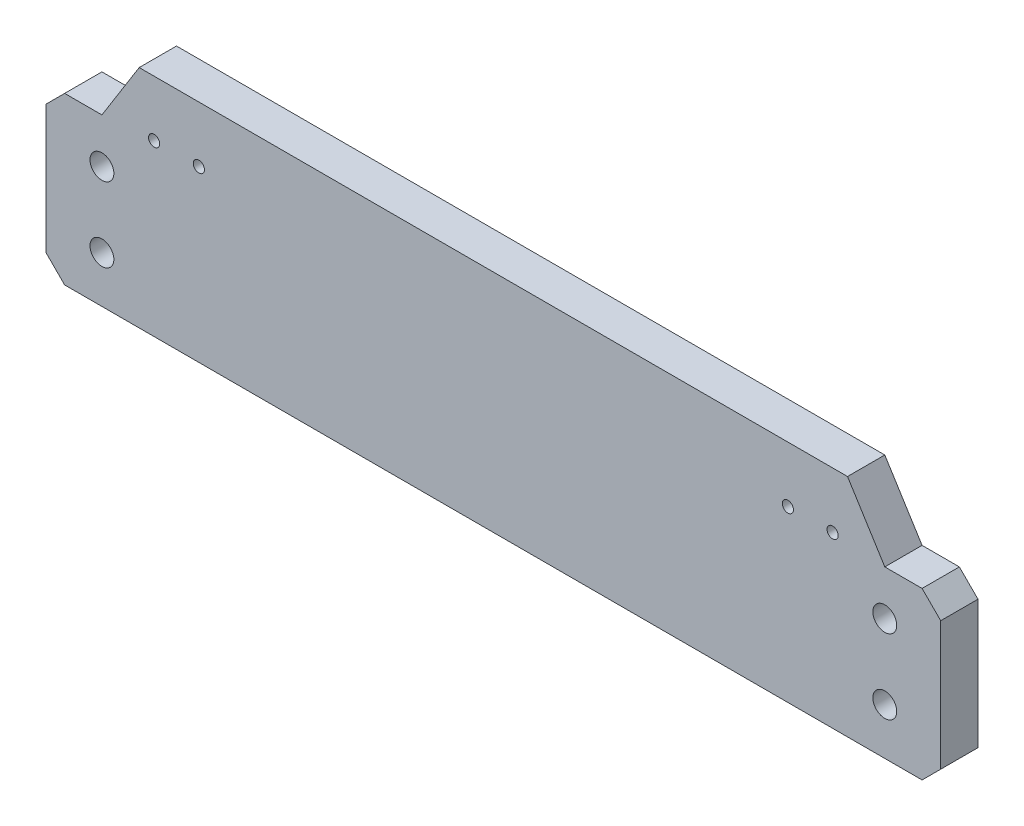
from build123d import *

# Parameters (mm, degrees)
SKETCH1_W           = 240
SKETCH1_H           = 60.5
SKETCH1_R           = 3.2
SKETCH1_R_2         = 1.5
BOSS_EXTRUDE1_DEPTH = 10
CUT_EXTRUDE1_DEPTH  = 11
CHAMFER3_SIZE       = 5


with BuildPart() as part:
    # Sketch1 → Boss-Extrude1 (new body)
    with BuildSketch(Plane.XY):
        Rectangle(SKETCH1_W, SKETCH1_H)
        with Locations((-105, 2.25)):
            Circle(SKETCH1_R, mode=Mode.SUBTRACT)
        with Locations((-105, -17.75)):
            Circle(SKETCH1_R, mode=Mode.SUBTRACT)
        with Locations((105, -17.75)):
            Circle(SKETCH1_R, mode=Mode.SUBTRACT)
        with Locations((105, 2.25)):
            Circle(SKETCH1_R, mode=Mode.SUBTRACT)
        with Locations((-91, 15.25)):
            Circle(SKETCH1_R_2, mode=Mode.SUBTRACT)
        with Locations((-79, 15.25)):
            Circle(SKETCH1_R_2, mode=Mode.SUBTRACT)
        with Locations((79, 15.25)):
            Circle(SKETCH1_R_2, mode=Mode.SUBTRACT)
        with Locations((91, 15.25)):
            Circle(SKETCH1_R_2, mode=Mode.SUBTRACT)
    extrude(amount=BOSS_EXTRUDE1_DEPTH)

    # Sketch2 → Cut-Extrude1 (cut, through all)
    with BuildSketch(Plane.XY.offset(10)):
        Polygon((-120, 14.25), (-105, 14.25), (-95, 30.25), (-120, 30.25), align=None)
        Polygon((120, 30.25), (120, 14.25), (105, 14.25), (95, 30.25), align=None)
    extrude(amount=-CUT_EXTRUDE1_DEPTH, mode=Mode.SUBTRACT)

    # Chamfer3
    chamfer3_edges = [part.edges().sort_by_distance(p)[0] for p in [
        (-120, 14.25, 5),
        (120, 14.25, 5),
        (120, -30.25, 5),
        (-120, -30.25, 5),
    ]]
    chamfer(chamfer3_edges, length=CHAMFER3_SIZE)


solid = part.part
